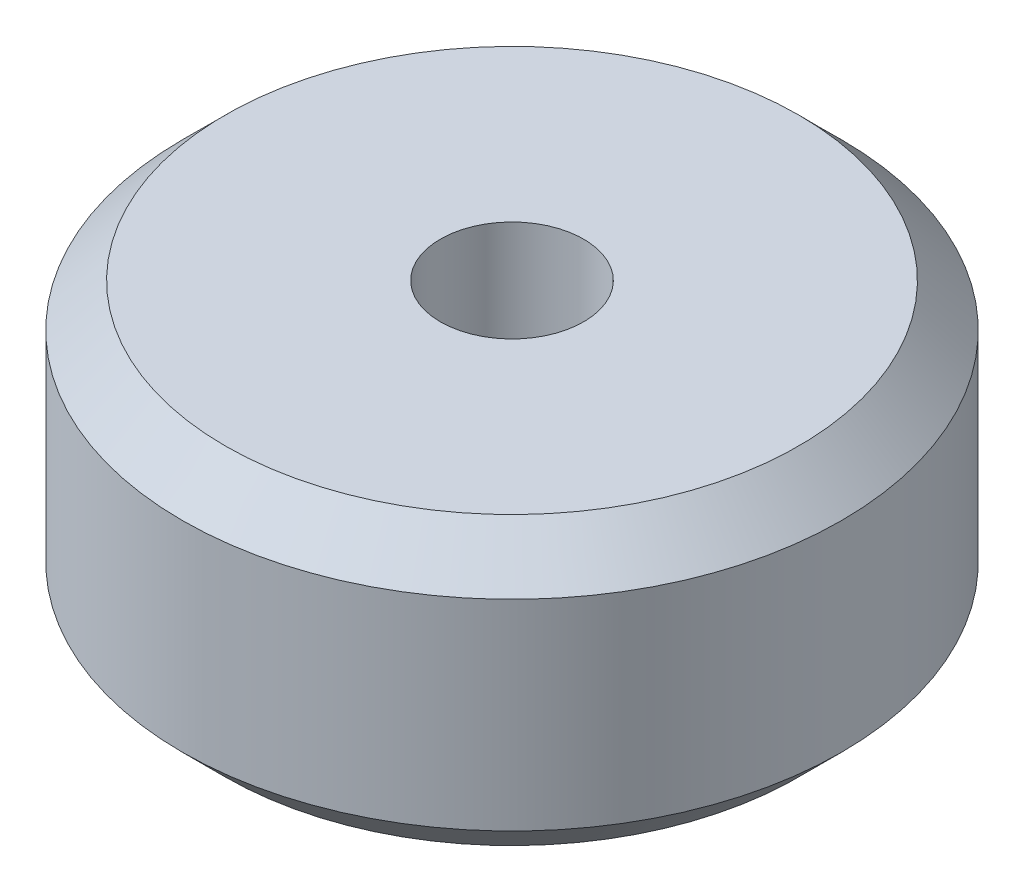
from build123d import *


with BuildPart() as part:
    # Sketch1 → Revolve1 (revolve)
    with BuildSketch(Plane.XY):
        Polygon((2.5, 5), (10, 5), (11.5, 3.5), (11.5, -3.5), (10, -5), (2.5, -5), align=None)
    revolve(axis=Axis((0, 50, 0), (0, -1, 0)))


solid = part.part
